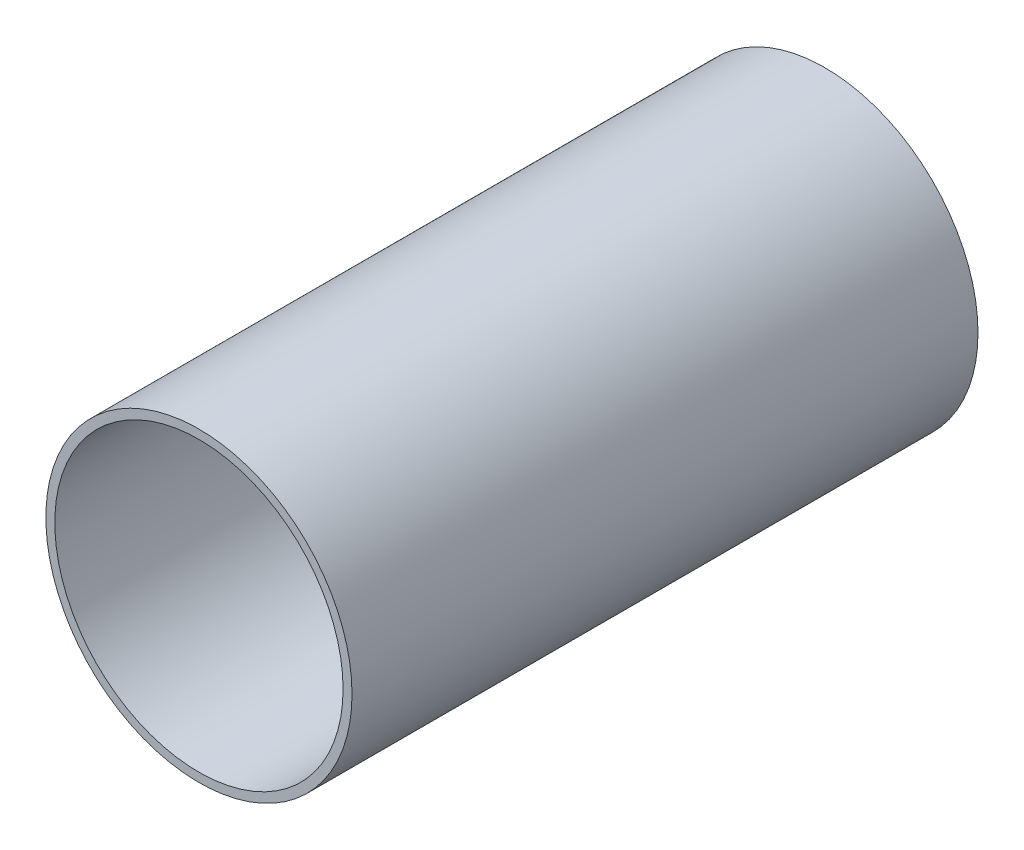
from build123d import *

# Parameters (mm, degrees)
SKETCH4_R           = 171.186451308
SKETCH4_R_2         = 161.186451308
EXTRUDE_THIN1_DEPTH = 700
SKETCH5_R           = 171.186451308
BOSS_EXTRUDE1_DEPTH = 10


with BuildPart() as part:
    # Sketch4 → Extrude-Thin1 (new body)
    with BuildSketch(Plane.XY):
        with Locations((12409.740446877, 3023.031510129)):
            Circle(SKETCH4_R)
        with Locations((12409.740446877, 3023.031510129)):
            Circle(SKETCH4_R_2, mode=Mode.SUBTRACT)
    extrude(amount=EXTRUDE_THIN1_DEPTH)

    # Sketch5 → Boss-Extrude1 (add)
    with BuildSketch(Plane.XY):
        with Locations((12409.740446877, 3023.031510129)):
            Circle(SKETCH5_R)
    extrude(amount=BOSS_EXTRUDE1_DEPTH)


solid = part.part
